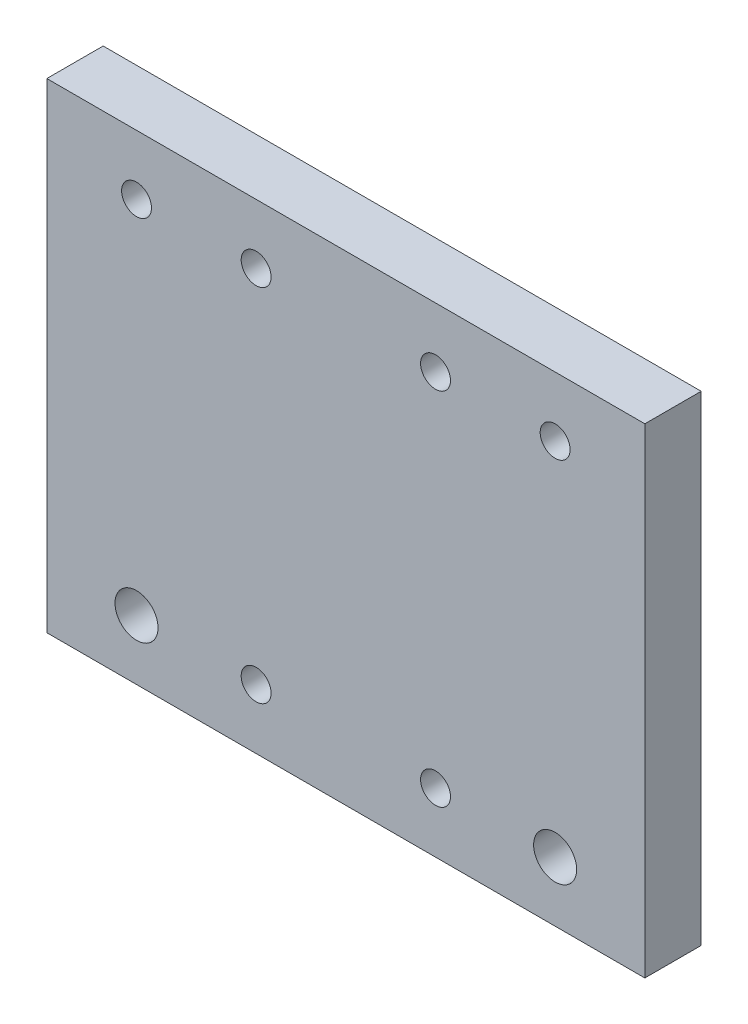
from build123d import *

# Parameters (mm, degrees)
SKETCH1_W           = 100
SKETCH1_H           = 80.26
SKETCH1_R           = 3.6
SKETCH1_R_2         = 2.5
BOSS_EXTRUDE1_DEPTH = 9.42
SKETCH2_R           = 2.5
CUT_EXTRUDE1_DEPTH  = 10.42


with BuildPart() as part:
    # Sketch1 → Boss-Extrude1 (new body)
    with BuildSketch(Plane.XY):
        with Locations((52.710746881, 14.822551686)):
            Rectangle(SKETCH1_W, SKETCH1_H)
        with Locations((17.710746881, -15.307448314)):
            Circle(SKETCH1_R, mode=Mode.SUBTRACT)
        with Locations((17.710746881, 44.952551686)):
            Circle(SKETCH1_R_2, mode=Mode.SUBTRACT)
        with Locations((87.710746881, 44.952551686)):
            Circle(SKETCH1_R_2, mode=Mode.SUBTRACT)
        with Locations((87.710746881, -15.307448314)):
            Circle(SKETCH1_R, mode=Mode.SUBTRACT)
    extrude(amount=BOSS_EXTRUDE1_DEPTH)

    # Sketch2 → Cut-Extrude1 (cut, through all)
    with BuildSketch(Plane.XY.offset(9.42)):
        with Locations((37.710746881, -15.307448314)):
            Circle(SKETCH2_R)
        with Locations((67.710746881, -15.307448314)):
            Circle(SKETCH2_R)
        with Locations((67.710746881, 44.952551686)):
            Circle(SKETCH2_R)
        with Locations((37.710746881, 44.952551686)):
            Circle(SKETCH2_R)
    extrude(amount=-CUT_EXTRUDE1_DEPTH, mode=Mode.SUBTRACT)


solid = part.part
